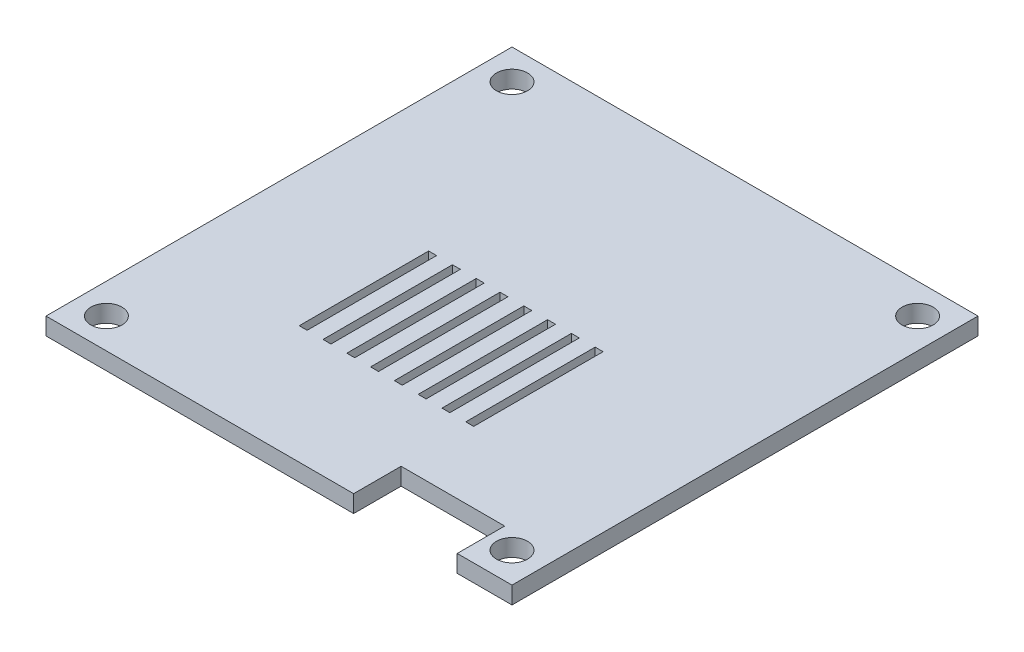
from build123d import *

# Parameters (mm, degrees)
SKETCH_3_W      = 0.91875
SKETCH_3_H      = 15
SKETCH_3_R      = 1.8
EXTRUDE_2_DEPTH = 2


with BuildPart() as part:
    # 草图3 → 凸台-拉伸2 (new body)
    with BuildSketch(Plane(origin=(0, 0, 0), x_dir=(1, 0, 0), z_dir=(0, 1, 0))):
        Polygon((8.65, -21.5), (20.65, -21.5), (20.65, -27), (27, -27), (27, 27), (-27, 27), (-27, -27), (8.65, -27), align=None)
        with Locations((-10.896875, -5.8)):
            Rectangle(SKETCH_3_W, SKETCH_3_H, mode=Mode.SUBTRACT)
        with Locations((-8.140625, -5.8)):
            Rectangle(SKETCH_3_W, SKETCH_3_H, mode=Mode.SUBTRACT)
        with Locations((-5.384375, -5.8)):
            Rectangle(SKETCH_3_W, SKETCH_3_H, mode=Mode.SUBTRACT)
        with Locations((-2.628125, -5.8)):
            Rectangle(SKETCH_3_W, SKETCH_3_H, mode=Mode.SUBTRACT)
        with Locations((0.128125, -5.8)):
            Rectangle(SKETCH_3_W, SKETCH_3_H, mode=Mode.SUBTRACT)
        with Locations((2.884375, -5.8)):
            Rectangle(SKETCH_3_W, SKETCH_3_H, mode=Mode.SUBTRACT)
        with Locations((5.640625, -5.8)):
            Rectangle(SKETCH_3_W, SKETCH_3_H, mode=Mode.SUBTRACT)
        with Locations((8.396875, -5.8)):
            Rectangle(SKETCH_3_W, SKETCH_3_H, mode=Mode.SUBTRACT)
        with Locations((23.5, 23.5)):
            Circle(SKETCH_3_R, mode=Mode.SUBTRACT)
        with Locations((23.5, -23.5)):
            Circle(SKETCH_3_R, mode=Mode.SUBTRACT)
        with Locations((-23.5, 23.5)):
            Circle(SKETCH_3_R, mode=Mode.SUBTRACT)
        with Locations((-23.5, -23.5)):
            Circle(SKETCH_3_R, mode=Mode.SUBTRACT)
    extrude(amount=EXTRUDE_2_DEPTH)


solid = part.part
